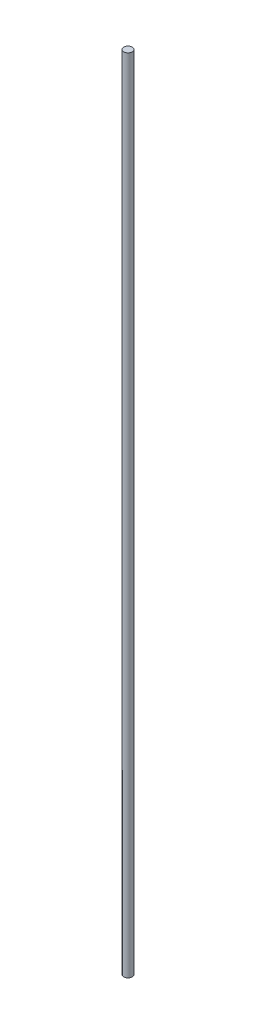
from build123d import *

# Parameters (mm, degrees)
SKETCH5_R = 0.5


with BuildPart() as part:
    # Sweep1: sweep along a path in Sketch3
    with BuildLine(Plane.XY) as sweep1_path:
        Line((0, 0), (0, 95))
    # Sketch5 → Sweep1 (sweep)
    with BuildSketch(Plane(origin=(0, 0, 0), x_dir=(1, 0, 0), z_dir=(0, 1, 0))):
        Circle(SKETCH5_R)
    sweep(path=sweep1_path.line)


solid = part.part
